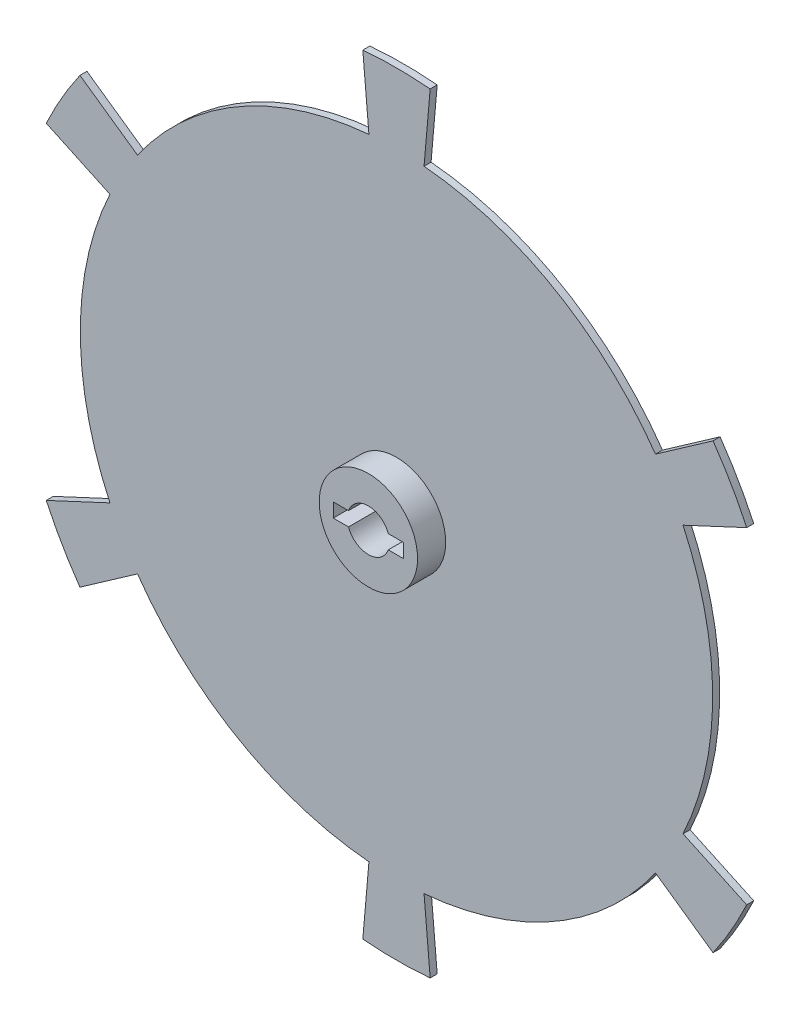
from build123d import *

# Parameters (mm, degrees)
SKETCH1_R           = 450
BOSS_EXTRUDE1_DEPTH = 10
SKETCH2_R           = 70
BOSS_EXTRUDE2_DEPTH = 40
BOSS_EXTRUDE3_DEPTH = 10


with BuildPart() as part:
    # Sketch1 → Boss-Extrude1 (new body)
    with BuildSketch(Plane.XY):
        Circle(SKETCH1_R)
        with BuildLine():
            Line((28.284271247, -10), (50, -10))
            Line((50, -10), (50, 10))
            Line((50, 10), (28.284271247, 10))
            ThreePointArc((28.284271247, 10), (0, 30), (-28.284271247, 10))
            Line((-28.284271247, 10), (-50, 10))
            Line((-50, 10), (-50, -10))
            Line((-50, -10), (-28.284271247, -10))
            ThreePointArc((-28.284271247, -10), (0, -30), (28.284271247, -10))
        make_face(mode=Mode.SUBTRACT)
    extrude(amount=BOSS_EXTRUDE1_DEPTH)

    # Sketch2 → Boss-Extrude2 (add)
    with BuildSketch(Plane.XY.offset(10)):
        Circle(SKETCH2_R)
        with BuildLine():
            Line((-50, 10), (-50, -10))
            Line((-50, -10), (-28.284271247, -10))
            ThreePointArc((-28.284271247, -10), (0, -30), (28.284271247, -10))
            Line((28.284271247, -10), (50, -10))
            Line((50, -10), (50, 10))
            Line((50, 10), (28.284271247, 10))
            ThreePointArc((28.284271247, 10), (0, 30), (-28.284271247, 10))
            Line((-28.284271247, 10), (-50, 10))
        make_face(mode=Mode.SUBTRACT)
    extrude(amount=BOSS_EXTRUDE2_DEPTH)

    # Sketch3 → Boss-Extrude3 (add)
    with BuildSketch(Plane.XY.offset(10)):
        with BuildLine():
            Line((-47.935658511, 547.90708395), (-34.862297099, 398.477879237))
            ThreePointArc((-34.862297099, 398.477879237), (-17.447754946, 399.619288633), (0, 400))
            ThreePointArc((0, 400), (17.447754946, 399.619288633), (34.862297099, 398.477879237))
            Line((34.862297099, 398.477879237), (47.935658511, 547.90708395))
            ThreePointArc((47.935658511, 547.90708395), (0, 550), (-47.935658511, 547.90708395))
        make_face()
        with BuildLine():
            Line((450.533624359, 315.467039993), (327.660817716, 229.43057454))
            ThreePointArc((327.660817716, 229.43057454), (346.410161514, 200), (362.523114815, 169.047304696))
            Line((362.523114815, 169.047304696), (498.46928287, 232.440043957))
            ThreePointArc((498.46928287, 232.440043957), (476.313972081, 275), (450.533624359, 315.467039993))
        make_face()
        with BuildLine():
            Line((498.46928287, -232.440043957), (362.523114815, -169.047304696))
            ThreePointArc((362.523114815, -169.047304696), (346.410161514, -200), (327.660817716, -229.43057454))
            Line((327.660817716, -229.43057454), (450.533624359, -315.467039993))
            ThreePointArc((450.533624359, -315.467039993), (476.313972081, -275), (498.46928287, -232.440043957))
        make_face()
        with BuildLine():
            Line((47.935658511, -547.90708395), (34.862297099, -398.477879237))
            ThreePointArc((34.862297099, -398.477879237), (0, -400), (-34.862297099, -398.477879237))
            Line((-34.862297099, -398.477879237), (-47.935658511, -547.90708395))
            ThreePointArc((-47.935658511, -547.90708395), (0, -550), (47.935658511, -547.90708395))
        make_face()
        with BuildLine():
            Line((-450.533624359, -315.467039993), (-327.660817716, -229.43057454))
            ThreePointArc((-327.660817716, -229.43057454), (-346.410161514, -200), (-362.523114815, -169.047304696))
            Line((-362.523114815, -169.047304696), (-498.46928287, -232.440043957))
            ThreePointArc((-498.46928287, -232.440043957), (-476.313972081, -275), (-450.533624359, -315.467039993))
        make_face()
        with BuildLine():
            Line((-498.46928287, 232.440043957), (-362.523114815, 169.047304696))
            ThreePointArc((-362.523114815, 169.047304696), (-346.410161514, 200), (-327.660817716, 229.43057454))
            Line((-327.660817716, 229.43057454), (-450.533624359, 315.467039993))
            ThreePointArc((-450.533624359, 315.467039993), (-476.313972081, 275), (-498.46928287, 232.440043957))
        make_face()
    extrude(amount=-BOSS_EXTRUDE3_DEPTH)


solid = part.part
